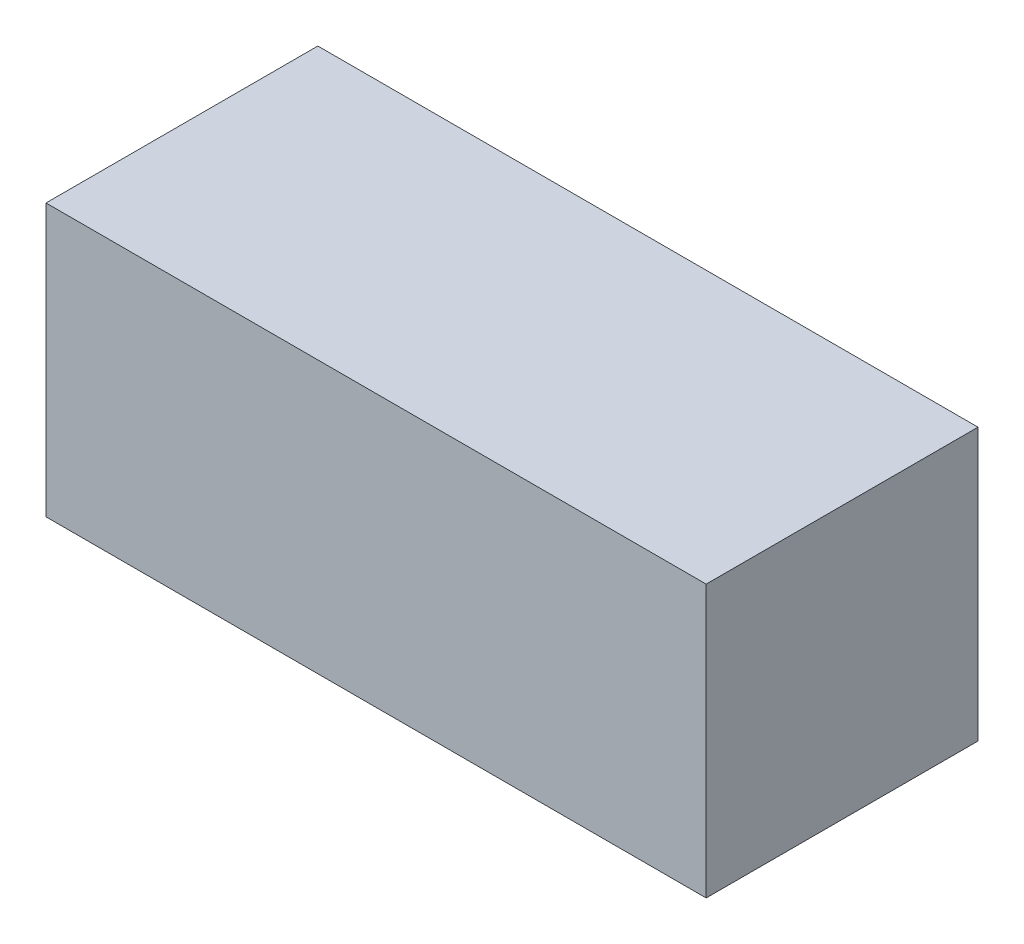
from build123d import *

# Parameters (mm, degrees)
SKETCH_1_W      = 170
SKETCH_1_H      = 70
EXTRUDE_1_DEPTH = 35


with BuildPart() as part:
    # Эскиз1 → Бобышка-Вытянуть1 (new body, symmetric)
    with BuildSketch(Plane.XY):
        Rectangle(SKETCH_1_W, SKETCH_1_H)
    extrude(amount=EXTRUDE_1_DEPTH, both=True)


solid = part.part
